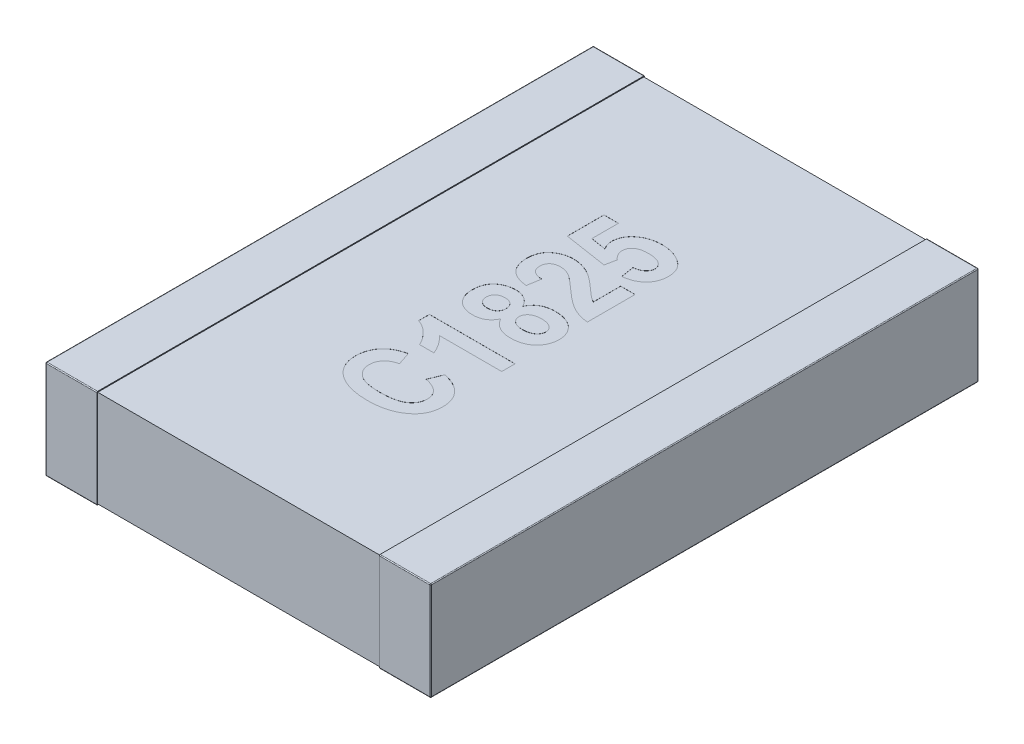
from build123d import *

# Parameters (mm, degrees)
SKETCH1_W            = 0.6
SKETCH1_H            = 6.4
THICKNESS_DEPTH      = 1.15
FILLET1_R            = 0.01
SKETCH2_W            = 6.38
SKETCH2_H            = 1.13
BOSS_EXTRUDE2_DEPTH  = 1.65
FILLET1_OF_MIRROR3_R = 0.01
CUT_EXTRUDE1_DEPTH   = 0.001


with BuildPart() as part:
    # Sketch1 → THICKNESS (new body)
    with BuildSketch(Plane(origin=(0, 0, 0), x_dir=(1, 0, 0), z_dir=(0, 1, 0))):
        with Locations((-1.95, 0)):
            Rectangle(SKETCH1_W, SKETCH1_H)
    thickness = extrude(amount=THICKNESS_DEPTH)

    # Fillet1
    fillet1_edges = [part.edges().sort_by_distance(p)[0] for p in [
        (-1.95, 1.15, -3.2),
        (-2.25, 1.15, 0),
        (-1.95, 0, -3.2),
        (-1.95, 0, 3.2),
        (-2.25, 0, 0),
        (-1.95, 1.15, 3.2),
        (-2.25, 0.575, -3.2),
        (-2.25, 0.575, 3.2),
    ]]
    fillet(fillet1_edges, radius=FILLET1_R)

    # Sketch2 → Boss-Extrude2 (add)
    with BuildSketch(Plane(origin=(0, 0, 0), x_dir=(0, 0, -1), z_dir=(1, 0, 0))):
        with Locations((0, 0.575)):
            Rectangle(SKETCH2_W, SKETCH2_H)
    boss_extrude2 = extrude(amount=-BOSS_EXTRUDE2_DEPTH)

    # Mirror3: THICKNESS, Boss-Extrude2 across plane
    add(thickness.mirror(Plane(origin=(0, 0, 0), x_dir=(0, 0, 1), z_dir=(1, 0, 0))))
    add(boss_extrude2.mirror(Plane(origin=(0, 0, 0), x_dir=(0, 0, 1), z_dir=(1, 0, 0))))

    # Fillet1 of Mirror3
    fillet1_of_mirror3_edges = [part.edges().sort_by_distance(p)[0] for p in [
        (1.95, 1.15, -3.2),
        (2.25, 1.15, 0),
        (1.95, 0, -3.2),
        (1.95, 0, 3.2),
        (2.25, 0, 0),
        (1.95, 1.15, 3.2),
        (2.25, 0.575, -3.2),
        (2.25, 0.575, 3.2),
    ]]
    fillet(fillet1_of_mirror3_edges, radius=FILLET1_OF_MIRROR3_R)

    # Sketch3 → Cut-Extrude1 (cut)
    with BuildSketch(Plane(origin=(0, 1.14, 0), x_dir=(1, 0, 0), z_dir=(0, 1, 0))):
        with BuildLine():
            Line((0.136363636, -1.13961039), (0.201298701, -0.983766234))
            add(Edge.make_bspline(
                [(0.201298701, -0.983766234), (0.214398679, -0.986985135), (0.239924634, -0.993257322), (0.276411029, -1.005118641), (0.310255179, -1.018188018), (0.341258619, -1.033054192), (0.369599325, -1.049483479), (0.395222463, -1.067525745), (0.418170449, -1.087112299), (0.438365598, -1.108268297), (0.455765912, -1.130956545), (0.471194946, -1.154625275), (0.484182898, -1.179628847), (0.4948407, -1.205978242), (0.502829618, -1.233620135), (0.508820757, -1.262435299), (0.512253899, -1.292530362), (0.512739893, -1.313032668), (0.512987013, -1.323457792)],
                knots=[0, 0, 0, 0, 4.0457e-05, 7.8832e-05, 0.000115008, 0.000149225, 0.00018187, 0.000213174, 0.000243107, 0.000272244, 0.000300738, 0.000328768, 0.000356904, 0.000385128, 0.000413894, 0.000443105, 0.000473335, 0.000504609, 0.000504609, 0.000504609, 0.000504609], degree=3))
            add(Edge.make_bspline(
                [(0.512987013, -1.323457792), (0.512692936, -1.336538079), (0.512116846, -1.362162052), (0.505918262, -1.399552352), (0.496500592, -1.435132443), (0.48297676, -1.468838191), (0.465690424, -1.500709563), (0.444278756, -1.530409865), (0.419538879, -1.558632129), (0.400249065, -1.575041432), (0.390422078, -1.583400974)],
                knots=[0, 0, 0, 0, 3.9207e-05, 7.6805e-05, 0.000113379, 0.00014944, 0.00018549, 0.000221864, 0.00025909, 0.000297748, 0.000297748, 0.000297748, 0.000297748], degree=3))
            add(Edge.make_bspline(
                [(0.390422078, -1.583400974), (0.378289428, -1.592589791), (0.353847085, -1.611101511), (0.313541703, -1.634341949), (0.270240344, -1.654108387), (0.223903762, -1.670286241), (0.17448062, -1.682896026), (0.121947356, -1.691711903), (0.066329381, -1.697006106), (0.028218004, -1.697698049), (0.008725649, -1.698051948)],
                knots=[0, 0, 0, 0, 4.5623e-05, 9.1911e-05, 0.00013922, 0.000188252, 0.000238945, 0.000292054, 0.000347905, 0.000406375, 0.000406375, 0.000406375, 0.000406375], degree=3))
            add(Edge.make_bspline(
                [(0.008725649, -1.698051948), (-0.011851286, -1.697728635), (-0.051931704, -1.697098877), (-0.110284982, -1.691428854), (-0.165298235, -1.682785146), (-0.216766987, -1.669897738), (-0.264986777, -1.65375342), (-0.309656912, -1.633807161), (-0.351244574, -1.610647553), (-0.376082128, -1.59175196), (-0.388392857, -1.582386364)],
                knots=[0, 0, 0, 0, 6.1715e-05, 0.000120211, 0.000175723, 0.00022863, 0.000279196, 0.000328068, 0.000375235, 0.000421589, 0.000421589, 0.000421589, 0.000421589], degree=3))
            add(Edge.make_bspline(
                [(-0.388392857, -1.582386364), (-0.398345965, -1.573883783), (-0.417961407, -1.55712702), (-0.443331204, -1.528469471), (-0.46499687, -1.497771098), (-0.482313096, -1.464708631), (-0.496435559, -1.429719195), (-0.506038208, -1.392403394), (-0.511790154, -1.352925698), (-0.512581962, -1.325912702), (-0.512987013, -1.312094156)],
                knots=[0, 0, 0, 0, 3.9231e-05, 7.7316e-05, 0.000114471, 0.000151689, 0.000189032, 0.000227423, 0.000266997, 0.000308443, 0.000308443, 0.000308443, 0.000308443], degree=3))
            add(Edge.make_bspline(
                [(-0.512987013, -1.312094156), (-0.512716343, -1.300786249), (-0.512184355, -1.27856109), (-0.507931398, -1.245971923), (-0.500453169, -1.214922729), (-0.490644065, -1.185110424), (-0.477519585, -1.156796563), (-0.461593795, -1.129899278), (-0.442919053, -1.104312793), (-0.428401184, -1.088804419), (-0.421063312, -1.080965909)],
                knots=[0, 0, 0, 0, 3.3918e-05, 6.6664e-05, 9.8361e-05, 0.000129612, 0.000160664, 0.000191777, 0.000223272, 0.000255459, 0.000255459, 0.000255459, 0.000255459], degree=3))
            add(Edge.make_bspline(
                [(-0.421063312, -1.080965909), (-0.415407881, -1.075515869), (-0.403883704, -1.06441022), (-0.384471947, -1.049456438), (-0.363093659, -1.035611831), (-0.339657607, -1.023124617), (-0.314392853, -1.011515651), (-0.28716989, -1.00095942), (-0.257926787, -0.991672878), (-0.237648602, -0.986442498), (-0.227272727, -0.983766234)],
                knots=[0, 0, 0, 0, 2.3548e-05, 4.7984e-05, 7.3368e-05, 9.988e-05, 0.000127573, 0.00015674, 0.000187416, 0.000219558, 0.000219558, 0.000219558, 0.000219558], degree=3))
            Line((-0.227272727, -0.983766234), (-0.175324675, -1.13961039))
            add(Edge.make_bspline(
                [(-0.175324675, -1.13961039), (-0.181975902, -1.141074849), (-0.194918084, -1.143924443), (-0.213595413, -1.149645704), (-0.230942941, -1.15661111), (-0.247377118, -1.164189563), (-0.262329513, -1.173315282), (-0.276514559, -1.182861071), (-0.28908196, -1.194054403), (-0.300692084, -1.205879848), (-0.310725155, -1.218754524), (-0.319798502, -1.231932912), (-0.327342325, -1.24580791), (-0.333409456, -1.260321642), (-0.338319598, -1.275302206), (-0.341772531, -1.290861229), (-0.34386351, -1.306963105), (-0.34405743, -1.317904873), (-0.344155844, -1.323457792)],
                knots=[0, 0, 0, 0, 2.0427e-05, 3.9747e-05, 5.8513e-05, 7.6485e-05, 9.3955e-05, 0.000111011, 0.000127695, 0.000144342, 0.000160663, 0.000176591, 0.0001923, 0.000207941, 0.000223727, 0.00023953, 0.000255689, 0.00027234, 0.00027234, 0.00027234, 0.00027234], degree=3))
            add(Edge.make_bspline(
                [(-0.344155844, -1.323457792), (-0.343922857, -1.331316567), (-0.343464314, -1.34678344), (-0.339815571, -1.369443473), (-0.333363218, -1.390883972), (-0.324888303, -1.411422831), (-0.313613243, -1.430733213), (-0.299927204, -1.448922482), (-0.283681663, -1.465818388), (-0.265141061, -1.481782958), (-0.243666159, -1.496411475), (-0.218738348, -1.508644713), (-0.190654932, -1.518900096), (-0.159545627, -1.527662188), (-0.125189618, -1.534232534), (-0.087627914, -1.538787955), (-0.046918653, -1.541632217), (-0.018673729, -1.542011522), (-0.004058442, -1.542207792)],
                knots=[0, 0, 0, 0, 2.357e-05, 4.6389e-05, 6.8605e-05, 9.0614e-05, 0.00011289, 0.000135495, 0.000158747, 0.000183068, 0.000208789, 0.000236468, 0.000266132, 0.000298382, 0.000333323, 0.000370951, 0.000411838, 0.00045568, 0.00045568, 0.00045568, 0.00045568], degree=3))
            add(Edge.make_bspline(
                [(-0.004058442, -1.542207792), (0.011095871, -1.541985985), (0.040278488, -1.541558851), (0.08242797, -1.539069004), (0.121153689, -1.534336396), (0.156607918, -1.528278299), (0.188583424, -1.51998836), (0.217099791, -1.509860599), (0.242435415, -1.498195029), (0.264257887, -1.484279255), (0.283097178, -1.468860302), (0.299453787, -1.452467135), (0.313117458, -1.434783266), (0.32469734, -1.416281785), (0.333472268, -1.39645475), (0.339442532, -1.375536726), (0.343571874, -1.353651768), (0.343958581, -1.338629112), (0.344155844, -1.330965909)],
                knots=[0, 0, 0, 0, 4.5466e-05, 8.7553e-05, 0.000126592, 0.000162456, 0.000195383, 0.00022555, 0.000253145, 0.000278871, 0.000302958, 0.000326059, 0.000348182, 0.000369864, 0.000391395, 0.00041297, 0.000435022, 0.000457984, 0.000457984, 0.000457984, 0.000457984], degree=3))
            add(Edge.make_bspline(
                [(0.344155844, -1.330965909), (0.343974101, -1.325347695), (0.343613575, -1.314202733), (0.341524436, -1.297749638), (0.337179679, -1.282037059), (0.33212763, -1.266651473), (0.324835159, -1.252083413), (0.316327699, -1.237949716), (0.306090095, -1.224513466), (0.294241166, -1.211708849), (0.280890082, -1.199504127), (0.265656465, -1.188231761), (0.248554845, -1.177946712), (0.229614222, -1.168426308), (0.208948136, -1.159715932), (0.186414075, -1.152031267), (0.162119865, -1.145078743), (0.145114413, -1.141468283), (0.136363636, -1.13961039)],
                knots=[0, 0, 0, 0, 1.6862e-05, 3.345e-05, 4.9593e-05, 6.5701e-05, 8.1946e-05, 9.8338e-05, 0.00011514, 0.000132516, 0.000150616, 0.000169326, 0.000189267, 0.000210412, 0.000232874, 0.00025649, 0.000281799, 0.000308629, 0.000308629, 0.000308629, 0.000308629], degree=3))
        make_face()
        with BuildLine():
            Line((0.5, -0.464285714), (0.5, -0.62012987))
            Line((0.5, -0.62012987), (-0.227272727, -0.62012987))
            add(Edge.make_bspline(
                [(-0.227272727, -0.62012987), (-0.219342858, -0.627689344), (-0.20361607, -0.642681549), (-0.181634885, -0.666514096), (-0.1614458, -0.691276106), (-0.142523528, -0.716727635), (-0.125651852, -0.743288732), (-0.110083792, -0.770585063), (-0.096240136, -0.79877629), (-0.088359948, -0.818199801), (-0.084415584, -0.827922078)],
                knots=[0, 0, 0, 0, 3.2861e-05, 6.5172e-05, 9.7182e-05, 0.000128677, 0.000160255, 0.000191516, 0.000222916, 0.000254385, 0.000254385, 0.000254385, 0.000254385], degree=3))
            Line((-0.084415584, -0.827922078), (-0.253246753, -0.827922078))
            add(Edge.make_bspline(
                [(-0.253246753, -0.827922078), (-0.258230882, -0.816716882), (-0.268607555, -0.793388299), (-0.289398529, -0.759179198), (-0.31572517, -0.724842225), (-0.340718585, -0.696157451), (-0.362998776, -0.673856163), (-0.380528209, -0.657945041), (-0.399040647, -0.643790102), (-0.417732271, -0.63046856), (-0.437430229, -0.618895324), (-0.457622557, -0.608601674), (-0.478442702, -0.599481282), (-0.492788832, -0.594721885), (-0.5, -0.592329545)],
                knots=[0, 0, 0, 0, 3.6765e-05, 7.6542e-05, 0.000119724, 0.000166455, 0.000190561, 0.000214271, 0.000237408, 0.000260432, 0.000283088, 0.000305867, 0.000328408, 0.000351191, 0.000351191, 0.000351191, 0.000351191], degree=3))
            Line((-0.5, -0.592329545), (-0.5, -0.464285714))
            Line((-0.5, -0.464285714), (0.5, -0.464285714))
        make_face()
        with BuildLine():
            add(Edge.make_bspline(
                [(-0.037743506, -0.092532468), (-0.042861167, -0.102453102), (-0.052812908, -0.121744649), (-0.072340437, -0.147098473), (-0.094123124, -0.169008365), (-0.118962733, -0.186708015), (-0.146304705, -0.200823607), (-0.176435191, -0.210374249), (-0.209104592, -0.216449855), (-0.231775961, -0.217163313), (-0.243506494, -0.217532468)],
                knots=[0, 0, 0, 0, 3.3427e-05, 6.5002e-05, 9.5566e-05, 0.000125807, 0.000156119, 0.000187498, 0.000220295, 0.000255459, 0.000255459, 0.000255459, 0.000255459], degree=3))
            add(Edge.make_bspline(
                [(-0.243506494, -0.217532468), (-0.253053504, -0.217363546), (-0.271665084, -0.217034238), (-0.298834275, -0.213716405), (-0.324497932, -0.208244706), (-0.348741255, -0.200702395), (-0.371674912, -0.191291346), (-0.39282754, -0.179106694), (-0.412614747, -0.165129176), (-0.4306937, -0.149047074), (-0.446964258, -0.131166444), (-0.46119515, -0.111648613), (-0.473313904, -0.090583172), (-0.482922811, -0.067968376), (-0.490796868, -0.044040862), (-0.496163142, -0.018594382), (-0.499507818, 0.008365065), (-0.499833111, 0.026843047), (-0.5, 0.036323052)],
                knots=[0, 0, 0, 0, 2.863e-05, 5.5813e-05, 8.1962e-05, 0.00010725, 0.000131897, 0.000156161, 0.000180316, 0.000204465, 0.000228598, 0.000252707, 0.000276794, 0.000301334, 0.000326297, 0.000352247, 0.000379229, 0.000407656, 0.000407656, 0.000407656, 0.000407656], degree=3))
            add(Edge.make_bspline(
                [(-0.5, 0.036323052), (-0.499773157, 0.046346218), (-0.499333375, 0.065778227), (-0.495736875, 0.094005243), (-0.490346368, 0.120498935), (-0.481729647, 0.144974073), (-0.47160251, 0.167898263), (-0.458597983, 0.188711239), (-0.44353399, 0.207831716), (-0.425963806, 0.224706418), (-0.40703877, 0.239908995), (-0.386738638, 0.252902185), (-0.365566611, 0.264205068), (-0.34332328, 0.27328228), (-0.320056355, 0.280214423), (-0.295903618, 0.285285618), (-0.270644014, 0.288400805), (-0.253458585, 0.288772251), (-0.244724026, 0.288961039)],
                knots=[0, 0, 0, 0, 3.0057e-05, 5.8272e-05, 8.5257e-05, 0.00011099, 0.000135962, 0.00016029, 0.000184407, 0.000208802, 0.000233204, 0.000257125, 0.000280999, 0.000305116, 0.000329061, 0.000353736, 0.000379082, 0.000405279, 0.000405279, 0.000405279, 0.000405279], degree=3))
            add(Edge.make_bspline(
                [(-0.244724026, 0.288961039), (-0.2329862, 0.288637304), (-0.210129615, 0.288006907), (-0.177184259, 0.281193648), (-0.146465976, 0.270808592), (-0.118660413, 0.255492083), (-0.093387865, 0.237095358), (-0.071217349, 0.215317383), (-0.052248185, 0.190386643), (-0.042618518, 0.171764904), (-0.037743506, 0.162337662)],
                knots=[0, 0, 0, 0, 3.5164e-05, 6.8474e-05, 0.000100497, 0.000132094, 0.000163305, 0.000194013, 0.000225019, 0.000256811, 0.000256811, 0.000256811, 0.000256811], degree=3))
            add(Edge.make_bspline(
                [(-0.037743506, 0.162337662), (-0.031939428, 0.173516469), (-0.02059304, 0.195369905), (0.002053777, 0.223830334), (0.027277698, 0.248600118), (0.056665954, 0.268140633), (0.089306034, 0.283597605), (0.125552926, 0.294115646), (0.165137389, 0.300770735), (0.192679684, 0.301545677), (0.206980519, 0.301948052)],
                knots=[0, 0, 0, 0, 3.7705e-05, 7.3709e-05, 0.000108584, 0.000143366, 0.00017904, 0.000216533, 0.000256231, 0.000299106, 0.000299106, 0.000299106, 0.000299106], degree=3))
            add(Edge.make_bspline(
                [(0.206980519, 0.301948052), (0.221822048, 0.301622019), (0.250776828, 0.300985951), (0.292790687, 0.294182214), (0.332284879, 0.283900373), (0.368639572, 0.268711655), (0.401692526, 0.250221563), (0.430988145, 0.228324863), (0.456012371, 0.202975889), (0.476483419, 0.174364957), (0.4928691, 0.143468802), (0.504428094, 0.110354817), (0.511860375, 0.075479397), (0.512608092, 0.05151258), (0.512987013, 0.039366883)],
                knots=[0, 0, 0, 0, 4.4486e-05, 8.679e-05, 0.00012735, 0.000166655, 0.000204636, 0.000240715, 0.000276015, 0.000311045, 0.0003459, 0.000380558, 0.000415977, 0.000452368, 0.000452368, 0.000452368, 0.000452368], degree=3))
            add(Edge.make_bspline(
                [(0.512987013, 0.039366883), (0.512782488, 0.029814804), (0.512380392, 0.011035333), (0.508335356, -0.016471264), (0.502179641, -0.042766655), (0.493154912, -0.067738747), (0.481502601, -0.091369605), (0.467407244, -0.113789965), (0.450936172, -0.135045636), (0.431839392, -0.154574971), (0.410844763, -0.17251003), (0.38769485, -0.187965158), (0.362901841, -0.201196271), (0.33631498, -0.212003447), (0.30796211, -0.220334734), (0.277847189, -0.226066964), (0.246038905, -0.229885612), (0.224240536, -0.23030469), (0.213068182, -0.230519481)],
                knots=[0, 0, 0, 0, 2.8638e-05, 5.6302e-05, 8.3225e-05, 0.000109542, 0.000135769, 0.000162119, 0.000188868, 0.000216278, 0.000243923, 0.000271557, 0.000299608, 0.000328096, 0.000357503, 0.000388107, 0.000419973, 0.000453477, 0.000453477, 0.000453477, 0.000453477], degree=3))
            add(Edge.make_bspline(
                [(0.213068182, -0.230519481), (0.198700285, -0.230123086), (0.170879994, -0.229355553), (0.130717189, -0.222524959), (0.093637499, -0.211402838), (0.059716732, -0.19582334), (0.029502702, -0.175700982), (0.002722331, -0.151980207), (-0.020126978, -0.124152763), (-0.031829127, -0.103148317), (-0.037743506, -0.092532468)],
                knots=[0, 0, 0, 0, 4.3077e-05, 8.341e-05, 0.000121797, 0.00015893, 0.000194949, 0.000230304, 0.000265927, 0.000302329, 0.000302329, 0.000302329, 0.000302329], degree=3))
        make_face()
        with BuildLine():
            add(Edge.make_bspline(
                [(-0.228287338, -0.061688312), (-0.219326065, -0.061381339), (-0.202297956, -0.060798033), (-0.178351269, -0.055265326), (-0.157544498, -0.04620306), (-0.140461158, -0.033120149), (-0.126986235, -0.017433394), (-0.117182082, 0.000443783), (-0.111315279, 0.020334791), (-0.110703513, 0.034254016), (-0.11038961, 0.041396104)],
                knots=[0, 0, 0, 0, 2.6848e-05, 5.1016e-05, 7.3268e-05, 9.4413e-05, 0.000114992, 0.00013488, 0.000155172, 0.000176557, 0.000176557, 0.000176557, 0.000176557], degree=3))
            add(Edge.make_bspline(
                [(-0.11038961, 0.041396104), (-0.110706289, 0.048671526), (-0.111323553, 0.062852678), (-0.11713455, 0.083098191), (-0.126981764, 0.10122961), (-0.140446883, 0.117123591), (-0.157528436, 0.130396252), (-0.1783022, 0.139728184), (-0.202304257, 0.145197977), (-0.219328238, 0.14579153), (-0.228287338, 0.146103896)],
                knots=[0, 0, 0, 0, 2.1789e-05, 4.2471e-05, 6.2537e-05, 8.3271e-05, 0.000104539, 0.000126875, 0.000151043, 0.000177891, 0.000177891, 0.000177891, 0.000177891], degree=3))
            add(Edge.make_bspline(
                [(-0.228287338, 0.146103896), (-0.236976642, 0.145790408), (-0.253533483, 0.14519308), (-0.276841459, 0.139711772), (-0.297124693, 0.130447326), (-0.314076164, 0.117544219), (-0.327552091, 0.101939951), (-0.33706415, 0.084091544), (-0.343308333, 0.06453598), (-0.3438687, 0.050711968), (-0.344155844, 0.043628247)],
                knots=[0, 0, 0, 0, 2.6038e-05, 4.9614e-05, 7.1312e-05, 9.2457e-05, 0.000113036, 0.000132649, 0.000152804, 0.000173987, 0.000173987, 0.000173987, 0.000173987], degree=3))
            add(Edge.make_bspline(
                [(-0.344155844, 0.043628247), (-0.343748891, 0.036289291), (-0.342955915, 0.021988846), (-0.337261825, 0.001472751), (-0.327179049, -0.016727183), (-0.313700113, -0.032702668), (-0.296742325, -0.045927004), (-0.276298695, -0.054938438), (-0.253239066, -0.060853769), (-0.236850288, -0.061401913), (-0.228287338, -0.061688312)],
                knots=[0, 0, 0, 0, 2.2009e-05, 4.2887e-05, 6.3227e-05, 8.3961e-05, 0.000105229, 0.000127112, 0.000150539, 0.000176172, 0.000176172, 0.000176172, 0.000176172], degree=3))
        make_face(mode=Mode.SUBTRACT)
        with BuildLine():
            add(Edge.make_bspline(
                [(0.194399351, -0.074675325), (0.2006917, -0.074525796), (0.212953801, -0.074234405), (0.230867749, -0.072917879), (0.247685431, -0.070277983), (0.263323649, -0.066588476), (0.277927118, -0.06221117), (0.291304818, -0.056516869), (0.303598516, -0.049767603), (0.318140513, -0.039757699), (0.333237935, -0.025394261), (0.34728288, -0.006280754), (0.355635366, 0.015052881), (0.356639487, 0.029896503), (0.357142857, 0.037337662)],
                knots=[0, 0, 0, 0, 1.8882e-05, 3.6795e-05, 5.3843e-05, 6.9889e-05, 8.4973e-05, 9.9521e-05, 0.000113416, 0.000126982, 0.000152389, 0.00017553, 0.00019769, 0.000219965, 0.000219965, 0.000219965, 0.000219965], degree=3))
            add(Edge.make_bspline(
                [(0.357142857, 0.037337662), (0.356730175, 0.044784294), (0.355914905, 0.059495434), (0.347659868, 0.080328171), (0.334574339, 0.099051719), (0.320025064, 0.112756317), (0.305934615, 0.122228971), (0.293988879, 0.128816397), (0.280560949, 0.134011311), (0.266055537, 0.138452917), (0.250247017, 0.14193902), (0.233140629, 0.144236435), (0.214795369, 0.146000761), (0.202115055, 0.146068951), (0.195616883, 0.146103896)],
                knots=[0, 0, 0, 0, 2.2252e-05, 4.396e-05, 6.6137e-05, 9.0397e-05, 0.000103398, 0.000117018, 0.000131224, 0.000146502, 0.000162503, 0.000179721, 0.000198259, 0.000217743, 0.000217743, 0.000217743, 0.000217743], degree=3))
            add(Edge.make_bspline(
                [(0.195616883, 0.146103896), (0.184631675, 0.14573465), (0.163704714, 0.145031232), (0.133970328, 0.139196998), (0.107846181, 0.129102736), (0.085787313, 0.114989141), (0.067923732, 0.098244243), (0.05493707, 0.079076088), (0.046679233, 0.057863619), (0.045866214, 0.042890175), (0.045454545, 0.035308442)],
                knots=[0, 0, 0, 0, 3.2936e-05, 6.2743e-05, 9.044e-05, 0.000116446, 0.000140846, 0.000163358, 0.000185446, 0.000208102, 0.000208102, 0.000208102, 0.000208102], degree=3))
            add(Edge.make_bspline(
                [(0.045454545, 0.035308442), (0.045980021, 0.02787324), (0.047020401, 0.013152429), (0.054890679, -0.008011136), (0.068178449, -0.026941978), (0.085993945, -0.043838478), (0.108091886, -0.057757966), (0.133991988, -0.067737147), (0.163159778, -0.073588372), (0.183684182, -0.0743025), (0.194399351, -0.074675325)],
                knots=[0, 0, 0, 0, 2.2275e-05, 4.4102e-05, 6.6729e-05, 9.1128e-05, 0.000117306, 0.000144551, 0.00017396, 0.000206086, 0.000206086, 0.000206086, 0.000206086], degree=3))
        make_face(mode=Mode.SUBTRACT)
        with BuildLine():
            Line((0.331168831, 0.938311688), (0.5, 0.938311688))
            Line((0.5, 0.938311688), (0.5, 0.37987013))
            add(Edge.make_bspline(
                [(0.5, 0.37987013), (0.483371878, 0.381834981), (0.450160812, 0.385759346), (0.401416985, 0.397642509), (0.353798597, 0.413660833), (0.315024186, 0.431200959), (0.283716795, 0.448607339), (0.258172511, 0.464178526), (0.230990775, 0.482722121), (0.202208417, 0.504215966), (0.171398924, 0.528048752), (0.138885435, 0.554747579), (0.104639318, 0.5841734), (0.081403726, 0.604937879), (0.069399351, 0.615665584)],
                knots=[0, 0, 0, 0, 5.0192e-05, 0.000100248, 0.000150173, 0.000200756, 0.00022764, 0.000257605, 0.000290474, 0.000326311, 0.000365358, 0.00040732, 0.000452506, 0.000500804, 0.000500804, 0.000500804, 0.000500804], degree=3))
            add(Edge.make_bspline(
                [(0.069399351, 0.615665584), (0.060018232, 0.624076803), (0.042071313, 0.640168216), (0.016082491, 0.662802186), (-0.00728779, 0.683161374), (-0.028521986, 0.700596959), (-0.047176105, 0.715723315), (-0.06353451, 0.728259349), (-0.077455394, 0.738355408), (-0.086213896, 0.74375175), (-0.090097403, 0.746144481)],
                knots=[0, 0, 0, 0, 3.7799e-05, 7.2312e-05, 0.00010339, 0.000130775, 0.000154734, 0.000175433, 0.000192606, 0.000206286, 0.000206286, 0.000206286, 0.000206286], degree=3))
            add(Edge.make_bspline(
                [(-0.090097403, 0.746144481), (-0.100045175, 0.751697646), (-0.119463446, 0.762537549), (-0.150235139, 0.773825594), (-0.181062308, 0.781203922), (-0.201799466, 0.782049441), (-0.212053571, 0.782467532)],
                knots=[0, 0, 0, 0, 3.4128e-05, 6.6618e-05, 9.8026e-05, 0.000128749, 0.000128749, 0.000128749, 0.000128749], degree=3))
            add(Edge.make_bspline(
                [(-0.212053571, 0.782467532), (-0.22230063, 0.782112014), (-0.241698968, 0.781438995), (-0.268837794, 0.775562416), (-0.292263142, 0.765945147), (-0.311201971, 0.751811065), (-0.326112443, 0.734768875), (-0.336660208, 0.714906606), (-0.343144596, 0.692636053), (-0.343811987, 0.676925607), (-0.344155844, 0.668831169)],
                knots=[0, 0, 0, 0, 3.0708e-05, 5.8133e-05, 8.2859e-05, 0.000106074, 0.000128371, 0.000150251, 0.000173051, 0.000197284, 0.000197284, 0.000197284, 0.000197284], degree=3))
            add(Edge.make_bspline(
                [(-0.344155844, 0.668831169), (-0.343772419, 0.660056776), (-0.343037518, 0.643239115), (-0.336195521, 0.619585725), (-0.324916913, 0.599055799), (-0.308547663, 0.582232146), (-0.288097037, 0.568424545), (-0.262958615, 0.558455739), (-0.233609955, 0.551620913), (-0.212498526, 0.549713304), (-0.201298701, 0.548701299)],
                knots=[0, 0, 0, 0, 2.6272e-05, 5.0355e-05, 7.3159e-05, 9.5837e-05, 0.000120095, 0.000146662, 0.000176489, 0.000210192, 0.000210192, 0.000210192, 0.000210192], degree=3))
            Line((-0.201298701, 0.548701299), (-0.227272727, 0.392857143))
            add(Edge.make_bspline(
                [(-0.227272727, 0.392857143), (-0.238664931, 0.394162124), (-0.260764459, 0.396693633), (-0.292507359, 0.403396939), (-0.322012621, 0.411335587), (-0.349127549, 0.421275746), (-0.37388751, 0.433063551), (-0.396265212, 0.446738941), (-0.416637199, 0.461907619), (-0.43431516, 0.479335113), (-0.449781056, 0.498326001), (-0.463317835, 0.51875211), (-0.474637136, 0.540763823), (-0.484076171, 0.564169148), (-0.491064393, 0.589179916), (-0.496414197, 0.615541692), (-0.499431636, 0.643463256), (-0.499807758, 0.662533641), (-0.5, 0.672280844)],
                knots=[0, 0, 0, 0, 3.4382e-05, 6.6697e-05, 9.722e-05, 0.000125982, 0.00015321, 0.000179346, 0.00020455, 0.000229231, 0.000253603, 0.000277916, 0.000302603, 0.000327737, 0.000353492, 0.000380394, 0.00040836, 0.000437599, 0.000437599, 0.000437599, 0.000437599], degree=3))
            add(Edge.make_bspline(
                [(-0.5, 0.672280844), (-0.499707252, 0.682978561), (-0.49914014, 0.703702176), (-0.495333259, 0.73385063), (-0.488609048, 0.761838314), (-0.479514345, 0.787998811), (-0.467494659, 0.811948605), (-0.452919977, 0.834016842), (-0.435652695, 0.853933707), (-0.415760674, 0.87150867), (-0.39445374, 0.887200172), (-0.372035902, 0.90076048), (-0.349004815, 0.912555537), (-0.325006155, 0.921763657), (-0.30032419, 0.929172446), (-0.274925758, 0.934368488), (-0.248741747, 0.937814887), (-0.231004194, 0.938144371), (-0.221996753, 0.938311688)],
                knots=[0, 0, 0, 0, 3.2093e-05, 6.2171e-05, 9.0964e-05, 0.000118305, 0.000145076, 0.000171134, 0.000197458, 0.000223899, 0.000250604, 0.00027674, 0.000302423, 0.000328123, 0.00035374, 0.000379648, 0.000405824, 0.000432832, 0.000432832, 0.000432832, 0.000432832], degree=3))
            add(Edge.make_bspline(
                [(-0.221996753, 0.938311688), (-0.211773706, 0.938136899), (-0.191410581, 0.937788739), (-0.161178194, 0.934365425), (-0.131385861, 0.929161638), (-0.10202543, 0.92157759), (-0.072835323, 0.911723457), (-0.043622997, 0.899730742), (-0.014293782, 0.885518643), (0.010007277, 0.871524131), (0.030196203, 0.858984695), (0.04633337, 0.847818727), (0.063414235, 0.835093434), (0.081726202, 0.821165591), (0.100916784, 0.805489082), (0.121214355, 0.788446197), (0.142523538, 0.769977344), (0.156945101, 0.757055714), (0.164366883, 0.750405844)],
                knots=[0, 0, 0, 0, 3.0658e-05, 6.1067e-05, 9.116e-05, 0.00012133, 0.000151939, 0.000183517, 0.000216008, 0.000249634, 0.000267595, 0.000287295, 0.00030848, 0.000331493, 0.000356308, 0.000382809, 0.000411004, 0.000440899, 0.000440899, 0.000440899, 0.000440899], degree=3))
            add(Edge.make_bspline(
                [(0.164366883, 0.750405844), (0.171180839, 0.744230626), (0.184209265, 0.732423479), (0.203055408, 0.715906776), (0.219965729, 0.701025964), (0.234932252, 0.687847294), (0.248114972, 0.676392306), (0.259635965, 0.66695971), (0.269243968, 0.659184174), (0.283565888, 0.647761375), (0.30373791, 0.634112487), (0.322291451, 0.624243266), (0.331168831, 0.619521104)],
                knots=[0, 0, 0, 0, 2.7587e-05, 5.2747e-05, 7.5177e-05, 9.5163e-05, 0.000112573, 0.000127565, 0.000139829, 0.000149654, 0.000182523, 0.000212679, 0.000212679, 0.000212679, 0.000212679], degree=3))
            Line((0.331168831, 0.619521104), (0.331168831, 0.938311688))
        make_face()
        with BuildLine():
            Line((0.24025974, 1.042207792), (0.214285714, 1.198051948))
            add(Edge.make_bspline(
                [(0.214285714, 1.198051948), (0.224824693, 1.199381248), (0.245036856, 1.201930645), (0.273334007, 1.210292355), (0.298151616, 1.222113416), (0.319133957, 1.237275533), (0.335602985, 1.254875128), (0.348119517, 1.27335265), (0.355668208, 1.293143842), (0.356653788, 1.306758626), (0.357142857, 1.31351461)],
                knots=[0, 0, 0, 0, 3.1828e-05, 6.1041e-05, 8.8087e-05, 0.000113941, 0.000138201, 0.000160039, 0.000180583, 0.00020082, 0.00020082, 0.00020082, 0.00020082], degree=3))
            add(Edge.make_bspline(
                [(0.357142857, 1.31351461), (0.35698325, 1.317517906), (0.356669609, 1.325384682), (0.354274292, 1.336952297), (0.350754906, 1.348157629), (0.345238805, 1.358811286), (0.338623665, 1.369163651), (0.330354823, 1.379028214), (0.320530221, 1.388292818), (0.309399428, 1.397320764), (0.296579254, 1.405373636), (0.282195736, 1.412565029), (0.266211228, 1.418584974), (0.248597638, 1.42339603), (0.229491334, 1.427292883), (0.208791867, 1.429788906), (0.186512857, 1.431467761), (0.171134378, 1.431698417), (0.163149351, 1.431818182)],
                knots=[0, 0, 0, 0, 1.2e-05, 2.3581e-05, 3.5324e-05, 4.7121e-05, 5.9448e-05, 7.2127e-05, 8.5618e-05, 9.991e-05, 0.000115054, 0.000130935, 0.000148083, 0.000166201, 0.000185661, 0.000206527, 0.000228705, 0.000252657, 0.000252657, 0.000252657, 0.000252657], degree=3))
            add(Edge.make_bspline(
                [(0.163149351, 1.431818182), (0.155638128, 1.431693912), (0.14107115, 1.431452908), (0.120001887, 1.429816789), (0.100396303, 1.427249327), (0.08231014, 1.423490654), (0.065832976, 1.41828065), (0.050694057, 1.412566689), (0.037123979, 1.405408415), (0.02526427, 1.397001113), (0.014513324, 1.388177652), (0.005668889, 1.378255151), (-0.002202355, 1.368134663), (-0.008582055, 1.357239514), (-0.013423044, 1.345685195), (-0.016836258, 1.333546925), (-0.019259219, 1.320915918), (-0.01940595, 1.312241281), (-0.019480519, 1.307832792)],
                knots=[0, 0, 0, 0, 2.2533e-05, 4.3699e-05, 6.3357e-05, 8.1824e-05, 9.9026e-05, 0.000115154, 0.000130314, 0.000144893, 0.000158716, 0.000171929, 0.000184673, 0.000197132, 0.000209682, 0.000222142, 0.000234919, 0.000248123, 0.000248123, 0.000248123, 0.000248123], degree=3))
            add(Edge.make_bspline(
                [(-0.019480519, 1.307832792), (-0.019288214, 1.302204678), (-0.018905391, 1.29100079), (-0.015728115, 1.274436991), (-0.010633212, 1.258290548), (-0.003449867, 1.24256758), (0.005775665, 1.227282976), (0.016968452, 1.212436376), (0.030335615, 1.198137524), (0.040307377, 1.18924776), (0.045454545, 1.184659091)],
                knots=[0, 0, 0, 0, 1.6873e-05, 3.3589e-05, 5.0404e-05, 6.7567e-05, 8.5315e-05, 0.000103863, 0.000123247, 0.000143927, 0.000143927, 0.000143927, 0.000143927], degree=3))
            Line((0.045454545, 1.184659091), (0.019480519, 1.055194805))
            Line((0.019480519, 1.055194805), (-0.487012987, 1.133116883))
            Line((-0.487012987, 1.133116883), (-0.487012987, 1.561688312))
            Line((-0.487012987, 1.561688312), (-0.318181818, 1.561688312))
            Line((-0.318181818, 1.561688312), (-0.318181818, 1.251420455))
            Line((-0.318181818, 1.251420455), (-0.137581169, 1.22362013))
            add(Edge.make_bspline(
                [(-0.137581169, 1.22362013), (-0.143340147, 1.232875081), (-0.154523758, 1.250847672), (-0.166240843, 1.279554987), (-0.173860629, 1.308318039), (-0.174839856, 1.327673524), (-0.175324675, 1.337256494)],
                knots=[0, 0, 0, 0, 3.2646e-05, 6.3396e-05, 9.268e-05, 0.000121395, 0.000121395, 0.000121395, 0.000121395], degree=3))
            add(Edge.make_bspline(
                [(-0.175324675, 1.337256494), (-0.175109296, 1.345659809), (-0.174686831, 1.362142879), (-0.170799885, 1.386316654), (-0.165054231, 1.40965432), (-0.156438725, 1.43191984), (-0.145589307, 1.453295137), (-0.132296312, 1.473547611), (-0.116876446, 1.493125639), (-0.104785365, 1.504801404), (-0.09862013, 1.51075487)],
                knots=[0, 0, 0, 0, 2.5192e-05, 4.9414e-05, 7.3283e-05, 9.7177e-05, 0.000120863, 0.000145065, 0.000169753, 0.000195437, 0.000195437, 0.000195437, 0.000195437], degree=3))
            add(Edge.make_bspline(
                [(-0.09862013, 1.51075487), (-0.090317008, 1.517984096), (-0.073728999, 1.532426673), (-0.046044988, 1.550643327), (-0.016539454, 1.566141376), (0.014924387, 1.578660902), (0.048200563, 1.588821257), (0.083600362, 1.595432643), (0.120827493, 1.599902327), (0.146292926, 1.600396871), (0.159293831, 1.600649351)],
                knots=[0, 0, 0, 0, 3.2997e-05, 6.5921e-05, 9.9141e-05, 0.000132829, 0.000167367, 0.000203343, 0.000240722, 0.000279709, 0.000279709, 0.000279709, 0.000279709], degree=3))
            add(Edge.make_bspline(
                [(0.159293831, 1.600649351), (0.170193215, 1.600404324), (0.191843162, 1.599917616), (0.223919445, 1.596358277), (0.255411081, 1.590713118), (0.286192139, 1.582564086), (0.31631158, 1.572202026), (0.345750226, 1.559517765), (0.374490293, 1.544498265), (0.402268995, 1.527444971), (0.428317599, 1.508524986), (0.450915015, 1.486859657), (0.47016828, 1.46338005), (0.486125577, 1.437980357), (0.497953639, 1.410305756), (0.506859871, 1.380874507), (0.511888629, 1.349332303), (0.512614665, 1.327668647), (0.512987013, 1.316558442)],
                knots=[0, 0, 0, 0, 3.2693e-05, 6.494e-05, 9.6702e-05, 0.000128596, 0.000160362, 0.000192176, 0.000224669, 0.000257558, 0.000289904, 0.000321049, 0.000351189, 0.000380808, 0.000410705, 0.0004412, 0.00047286, 0.000506189, 0.000506189, 0.000506189, 0.000506189], degree=3))
            add(Edge.make_bspline(
                [(0.512987013, 1.316558442), (0.512837699, 1.307549013), (0.512543524, 1.289798893), (0.508852182, 1.263752197), (0.503540441, 1.238780232), (0.495775851, 1.214944312), (0.485488033, 1.192415171), (0.473360284, 1.170777709), (0.458841853, 1.150398938), (0.44216269, 1.13133113), (0.423533437, 1.113658935), (0.402906821, 1.097801217), (0.380497324, 1.083633803), (0.355941769, 1.07182305), (0.329773287, 1.06131436), (0.301574638, 1.053207693), (0.271675222, 1.046264209), (0.250910954, 1.043583094), (0.24025974, 1.042207792)],
                knots=[0, 0, 0, 0, 2.7008e-05, 5.321e-05, 7.8763e-05, 0.000103533, 0.000128237, 0.000152954, 0.000177841, 0.000203153, 0.000228847, 0.000254743, 0.000281092, 0.000308227, 0.000336375, 0.000365588, 0.00039616, 0.000428359, 0.000428359, 0.000428359, 0.000428359], degree=3))
        make_face()
    extrude(amount=-CUT_EXTRUDE1_DEPTH, mode=Mode.SUBTRACT)


solid = part.part
